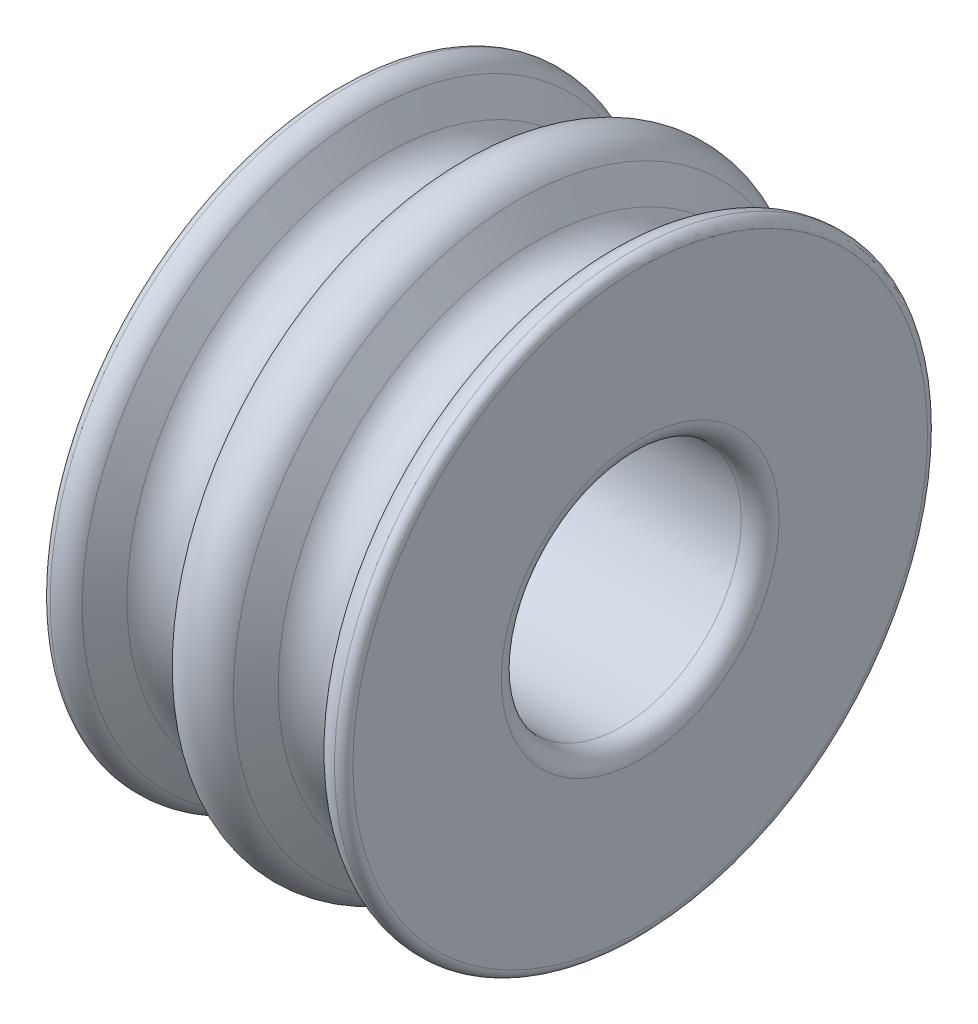
from build123d import *

# Parameters (mm, degrees)
SKETCH2_R          = 6.35
CUT_EXTRUDE1_DEPTH = 17.0000188
FILLET1_R          = 1.000000032


with BuildPart() as part:
    # Sketch1 → Revolve1 (revolve)
    with BuildSketch(Plane.XY):
        with BuildLine():
            ThreePointArc((-1.574269751, 15.101499778), (0, 16.010404842), (1.574269751, 15.101499778))
            Line((1.574269751, 15.101499778), (2.441162091, 13.5999982))
            ThreePointArc((2.441162091, 13.5999982), (4.0000047, 12.7), (5.558847309, 13.5999982))
            Line((5.558847309, 13.5999982), (6.425739649, 15.101499778))
            ThreePointArc((6.425739649, 15.101499778), (6.891177709, 15.55542644), (7.525040646, 15.699994))
            ThreePointArc((7.525040646, 15.699994), (7.862304547, 15.545211447), (8.0000094, 15.200621907))
            Line((8.0000094, 15.200621907), (8.0000094, 12.7))
            Line((8.0000094, 12.7), (8.0000094, 0))
            Line((8.0000094, 0), (-8.0000094, 0))
            Line((-8.0000094, 0), (-8.0000094, 12.7))
            Line((-8.0000094, 12.7), (-8.0000094, 15.200621907))
            ThreePointArc((-8.0000094, 15.200621907), (-7.862304547, 15.545211447), (-7.525040646, 15.699994))
            ThreePointArc((-7.525040646, 15.699994), (-6.891177709, 15.55542644), (-6.425739649, 15.101499778))
            Line((-6.425739649, 15.101499778), (-5.558847309, 13.5999982))
            ThreePointArc((-5.558847309, 13.5999982), (-4.0000047, 12.7), (-2.441162091, 13.5999982))
            Line((-2.441162091, 13.5999982), (-1.574269751, 15.101499778))
        make_face()
    revolve(axis=Axis((8.0000094, 0, 0), (-1, 0, 0)))

    # Sketch2 → Cut-Extrude1 (cut, through all)
    with BuildSketch(Plane(origin=(8.0000094, 0, 0), x_dir=(0, 0, -1), z_dir=(1, 0, 0))):
        Circle(SKETCH2_R)
    extrude(amount=-CUT_EXTRUDE1_DEPTH, mode=Mode.SUBTRACT)

    # Fillet1
    fillet1_edges = [part.edges().sort_by_distance(p)[0] for p in [
        (-8.0000094, 0, 6.35),
        (8.0000094, 0, 6.35),
    ]]
    fillet(fillet1_edges, radius=FILLET1_R)


solid = part.part
